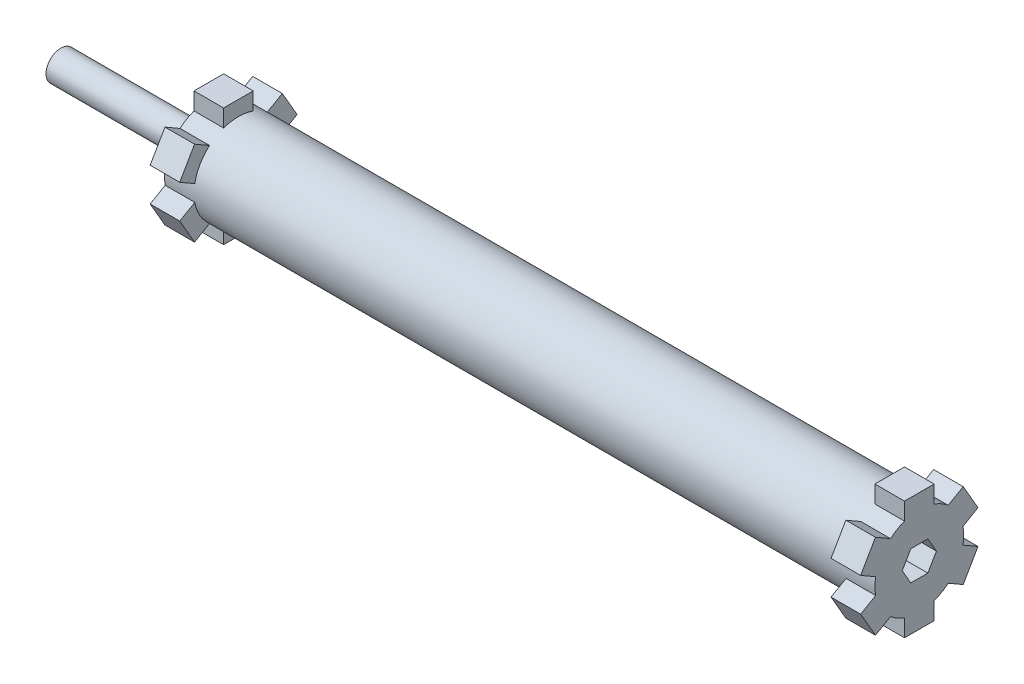
from build123d import *

# Parameters (mm, degrees)
ESBO_O1_R                 = 3
RESSALTO_EXTRUS_O1_DEPTH  = 48
ESBO_O2_W                 = 4
ESBO_O2_H                 = 2
RESSALTO_EXTRUS_O2_DEPTH  = 4
ESBO_O4_R                 = 4.471241999
CORTE_EXTRUS_O2_DEPTH     = 2
PADR_OCIRCULAR1_COUNT     = 6
ESBO_O7_R                 = 7.725132362
CORTE_EXTRUS_O3_DEPTH     = 2
ESPELHAR5_COPY_1_SKETCH_W = 4
ESPELHAR5_COPY_1_SKETCH_H = 2
ESPELHAR5_COPY_1_DEPTH    = 4
ESPELHAR5_COPY_2_SKETCH_W = 4
ESPELHAR5_COPY_2_SKETCH_H = 2
ESPELHAR5_COPY_2_DEPTH    = 4
ESPELHAR5_COPY_3_SKETCH_W = 4
ESPELHAR5_COPY_3_SKETCH_H = 2
ESPELHAR5_COPY_3_DEPTH    = 4
ESPELHAR5_COPY_4_SKETCH_W = 4
ESPELHAR5_COPY_4_SKETCH_H = 2
ESPELHAR5_COPY_4_DEPTH    = 4
ESPELHAR5_COPY_5_SKETCH_W = 4
ESPELHAR5_COPY_5_SKETCH_H = 2
ESPELHAR5_COPY_5_DEPTH    = 4
ESBO_O10_R                = 7.180900458
CORTE_EXTRUS_O5_DEPTH     = 2
ESBO_O11_R                = 1
RESSALTO_EXTRUS_O3_DEPTH  = 10
CORTE_EXTRUS_O6_DEPTH     = 3


with BuildPart() as part:
    # Esbo_o1 → Ressalto-extrus_o1 (new body)
    with BuildSketch(Plane(origin=(0, 0, 0), x_dir=(0, 0, -1), z_dir=(1, 0, 0))):
        Circle(ESBO_O1_R)
    ressalto_extrus_o1 = extrude(amount=RESSALTO_EXTRUS_O1_DEPTH)

    # Esbo_o2 → Ressalto-extrus_o2 (add, symmetric)
    with BuildSketch(Plane(origin=(0, 0, 0), x_dir=(1, 0, 0), z_dir=(0, 1, 0))):
        Rectangle(ESBO_O2_W, ESBO_O2_H)
    ressalto_extrus_o2 = extrude(amount=RESSALTO_EXTRUS_O2_DEPTH, both=True)

    # Esbo_o4 → Corte-extrus_o2 (cut)
    with BuildSketch(Plane.ZY.offset(2)):
        Circle(ESBO_O4_R)
    extrude(amount=-CORTE_EXTRUS_O2_DEPTH, mode=Mode.SUBTRACT)

    # Padr_oCircular1: Ressalto-extrus_o2 ×6 about axis
    padr_ocircular1_axis = Axis((0, 0, 0), (1, 0, 0))
    for i in range(1, PADR_OCIRCULAR1_COUNT):
        add(ressalto_extrus_o2.rotate(padr_ocircular1_axis, i * 360 / PADR_OCIRCULAR1_COUNT))

    # Esbo_o7 → Corte-extrus_o3 (cut)
    with BuildSketch(Plane.ZY.offset(2)):
        Circle(ESBO_O7_R)
    extrude(amount=-CORTE_EXTRUS_O3_DEPTH, mode=Mode.SUBTRACT)

    # Espelhar5: Ressalto-extrus_o1, Ressalto-extrus_o2 across plane
    add(ressalto_extrus_o1.mirror(Plane(origin=(24, 0, 0), x_dir=(0, 0, 1), z_dir=(1, 0, 0))))
    add(ressalto_extrus_o2.mirror(Plane(origin=(24, 0, 0), x_dir=(0, 0, 1), z_dir=(1, 0, 0))))

    # Espelhar5 copy 1 sketch → Espelhar5 copy 1 (add, symmetric)
    with BuildSketch(Plane(origin=(48, 0, 0), x_dir=(-1, 0, 0), z_dir=(0, 0.5, 0.866025404))):
        Rectangle(ESPELHAR5_COPY_1_SKETCH_W, ESPELHAR5_COPY_1_SKETCH_H)
    extrude(amount=ESPELHAR5_COPY_1_DEPTH, both=True)

    # Espelhar5 copy 2 sketch → Espelhar5 copy 2 (add, symmetric)
    with BuildSketch(Plane(origin=(48, 0, 0), x_dir=(-1, 0, 0), z_dir=(0, -0.5, 0.866025404))):
        Rectangle(ESPELHAR5_COPY_2_SKETCH_W, ESPELHAR5_COPY_2_SKETCH_H)
    extrude(amount=ESPELHAR5_COPY_2_DEPTH, both=True)

    # Espelhar5 copy 3 sketch → Espelhar5 copy 3 (add, symmetric)
    with BuildSketch(Plane(origin=(48, 0, 0), x_dir=(-1, 0, 0), z_dir=(0, -1, 0))):
        Rectangle(ESPELHAR5_COPY_3_SKETCH_W, ESPELHAR5_COPY_3_SKETCH_H)
    extrude(amount=ESPELHAR5_COPY_3_DEPTH, both=True)

    # Espelhar5 copy 4 sketch → Espelhar5 copy 4 (add, symmetric)
    with BuildSketch(Plane(origin=(48, 0, 0), x_dir=(-1, 0, 0), z_dir=(0, -0.5, -0.866025404))):
        Rectangle(ESPELHAR5_COPY_4_SKETCH_W, ESPELHAR5_COPY_4_SKETCH_H)
    extrude(amount=ESPELHAR5_COPY_4_DEPTH, both=True)

    # Espelhar5 copy 5 sketch → Espelhar5 copy 5 (add, symmetric)
    with BuildSketch(Plane(origin=(48, 0, 0), x_dir=(-1, 0, 0), z_dir=(0, 0.5, -0.866025404))):
        Rectangle(ESPELHAR5_COPY_5_SKETCH_W, ESPELHAR5_COPY_5_SKETCH_H)
    extrude(amount=ESPELHAR5_COPY_5_DEPTH, both=True)

    # Esbo_o10 → Corte-extrus_o5 (cut)
    with BuildSketch(Plane(origin=(50, 0, 0), x_dir=(0, 0, -1), z_dir=(1, 0, 0))):
        Circle(ESBO_O10_R)
    extrude(amount=-CORTE_EXTRUS_O5_DEPTH, mode=Mode.SUBTRACT)

    # Esbo_o11 → Ressalto-extrus_o3 (add)
    with BuildSketch(Plane.ZY):
        Circle(ESBO_O11_R)
    extrude(amount=RESSALTO_EXTRUS_O3_DEPTH)

    # Esbo_o12 → Corte-extrus_o6 (cut)
    with BuildSketch(Plane(origin=(48, 0, 0), x_dir=(0, 0, -1), z_dir=(1, 0, 0))):
        Polygon((-0.577350269, 1), (-1.154700538, 0), (-0.577350269, -1), (0.577350269, -1), (1.154700538, 0), (0.577350269, 1), align=None)
    extrude(amount=-CORTE_EXTRUS_O6_DEPTH, mode=Mode.SUBTRACT)


solid = part.part
